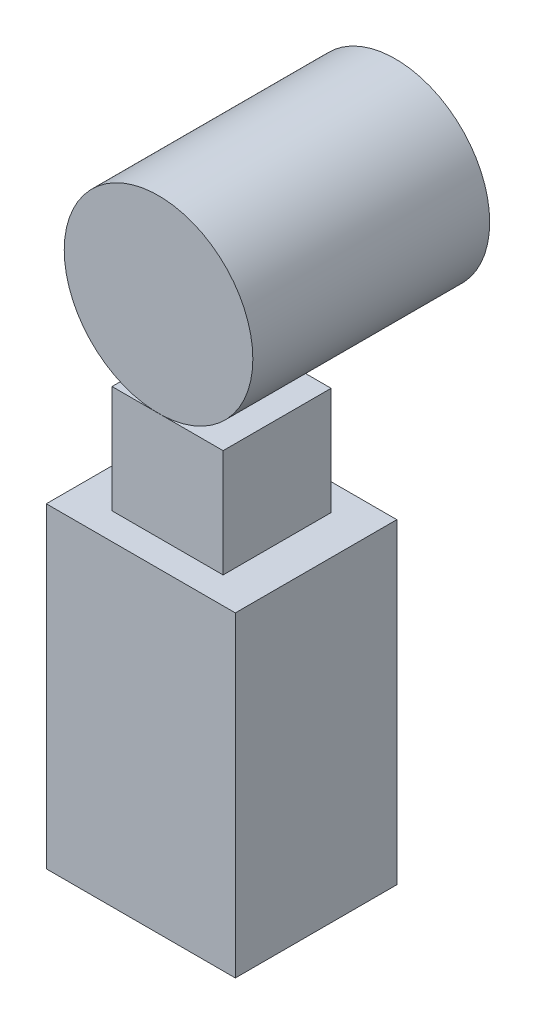
from build123d import *

# Parameters (mm, degrees)
SKETCH1_W           = 70.230746482
SKETCH1_H           = 117.476103032
BOSS_EXTRUDE1_DEPTH = 60
SKETCH2_W           = 41.272842477
SKETCH2_H           = 40.131406686
BOSS_EXTRUDE2_DEPTH = 40
SKETCH4_R           = 35.037863264
BOSS_EXTRUDE4_DEPTH = 88


with BuildPart() as part:
    # Sketch1 → Boss-Extrude1 (new body)
    with BuildSketch(Plane.XY):
        with Locations((-16.436427192, -13.121363424)):
            Rectangle(SKETCH1_W, SKETCH1_H)
    extrude(amount=BOSS_EXTRUDE1_DEPTH)

    # Sketch2 → Boss-Extrude2 (add)
    with BuildSketch(Plane(origin=(0, 45.616688092, 0), x_dir=(1, 0, 0), z_dir=(0, 1, 0))):
        with Locations((-16.436427192, -30)):
            Rectangle(SKETCH2_W, SKETCH2_H)
    extrude(amount=BOSS_EXTRUDE2_DEPTH)


with BuildPart() as body_2:
    # Sketch4 → Boss-Extrude4 (new body)
    with BuildSketch(Plane.XY.offset(50.065703343)):
        with Locations((-19.789623092, 120.654551356)):
            Circle(SKETCH4_R)
    extrude(amount=-BOSS_EXTRUDE4_DEPTH)


solid = Compound([part.part, body_2.part])
